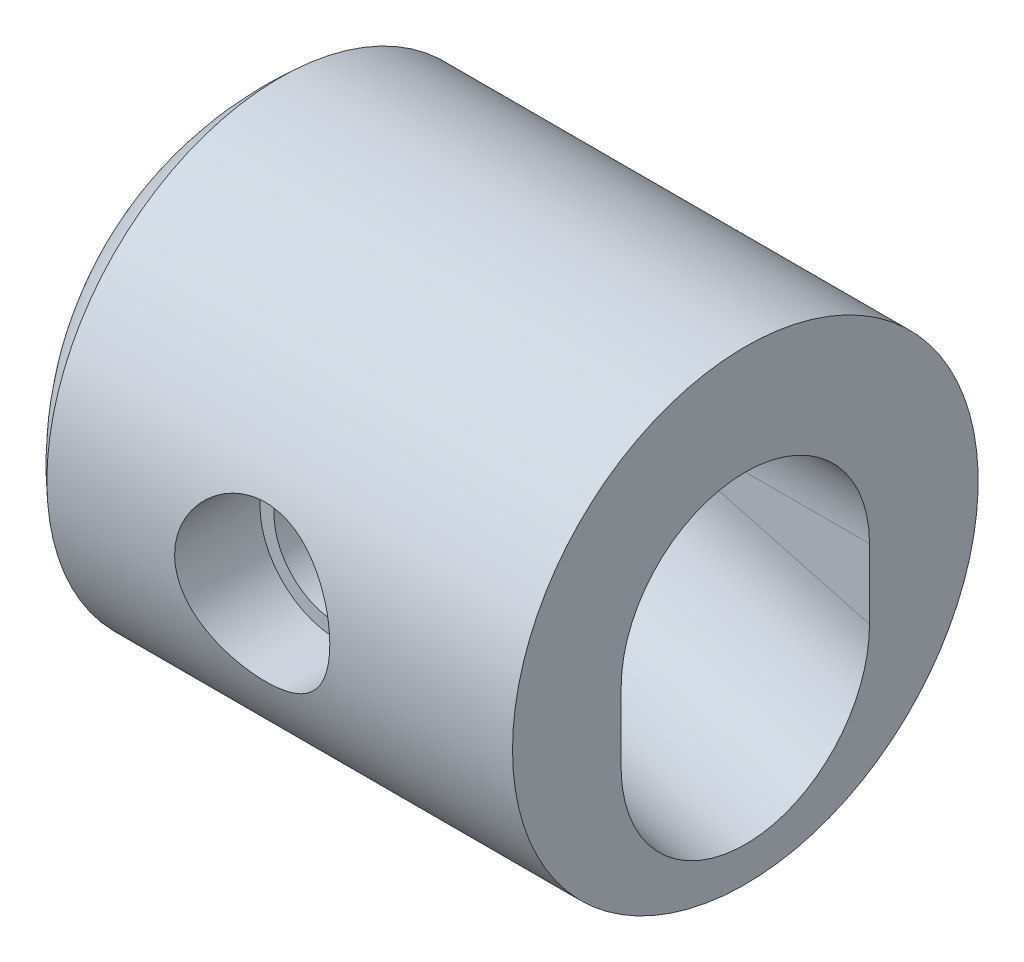
from build123d import *

# Parameters (mm, degrees)
SCHNITT_LINEAR_AUSTRAGEN1_DEPTH      = 29.03569171
SCHNITT_LINEAR_AUSTRAGEN1_DEPTH_BACK = 29.03569171
SKIZZE8_R                            = 8
SCHNITT_LINEAR_AUSTRAGEN2_DEPTH      = 8
SCHNITT_LINEAR_AUSTRAGEN2_DEPTH_BACK = 8


with BuildPart() as part:
    # Skizze4 → Rotation1 (revolve)
    with BuildSketch(Plane(origin=(0, 0, 0), x_dir=(1, 0, 0), z_dir=(0, 1, 0))):
        with BuildLine():
            Line((-13.228756555, 15), (16.771243445, 15))
            Line((16.771243445, 15), (16.771243445, 8))
            Line((16.771243445, 8), (-18.33030278, 8))
            ThreePointArc((-18.33030278, 8), (-16.163030549, 11.779492496), (-13.228756555, 15))
        make_face()
    revolve(axis=Axis((-20, 0, 0), (1, 0, 0)))

    # Skizze6 → Schnitt-Rotation1 (revolve, cut)
    with BuildSketch(Plane(origin=(0, 0, 0), x_dir=(1, 0, 0), z_dir=(0, 1, 0))):
        Polygon((-4.1, 9.5), (-4.1, -9.5), (-5, -9.5), (-5, -15), (0, -15), (0, 15), (-5, 15), (-5, 9.5), align=None)
    revolve(axis=Axis((0, 0, -15), (0, 0, 1)), mode=Mode.SUBTRACT)

    # Skizze8 → Schnitt-Linear austragen1 (cut, two sides: drawn at the far end of the back side and taken through both)
    with BuildSketch(Plane(origin=(0, 0, 0), x_dir=(0, 0, -1), z_dir=(0.9659258262890682, -0.25881904510252124, 0)).offset(-SCHNITT_LINEAR_AUSTRAGEN1_DEPTH_BACK)):
        Circle(SKIZZE8_R)
    extrude(amount=SCHNITT_LINEAR_AUSTRAGEN1_DEPTH + SCHNITT_LINEAR_AUSTRAGEN1_DEPTH_BACK, mode=Mode.SUBTRACT)

    # Skizze9 → Schnitt-Linear austragen2 (cut, two sides: drawn at the far end of the back side and taken through both)
    with BuildSketch(Plane.XY.offset(-SCHNITT_LINEAR_AUSTRAGEN2_DEPTH_BACK)):
        with BuildLine():
            Line((-17.705712859, 4.744231462), (-3.960295888, 1.061158085))
            ThreePointArc((-3.960295888, 1.061158085), (-4.064923932, 0.535157388), (-4.1, 0))
            Line((-4.1, 0), (-18.33030278, 0))
            Line((-18.33030278, 0), (-18.33030278, 2.413230142))
            Line((-18.33030278, 2.413230142), (-17.705712859, 4.744231462))
        make_face()
        with BuildLine():
            Line((16.771243445, -4.493841137), (16.771243445, 0))
            Line((16.771243445, 0), (4.1, 0))
            ThreePointArc((4.1, 0), (4.064923932, -0.535157388), (3.960295888, -1.061158085))
            Line((3.960295888, -1.061158085), (16.771243445, -4.493841137))
        make_face()
    extrude(amount=SCHNITT_LINEAR_AUSTRAGEN2_DEPTH + SCHNITT_LINEAR_AUSTRAGEN2_DEPTH_BACK, mode=Mode.SUBTRACT)


solid = part.part
